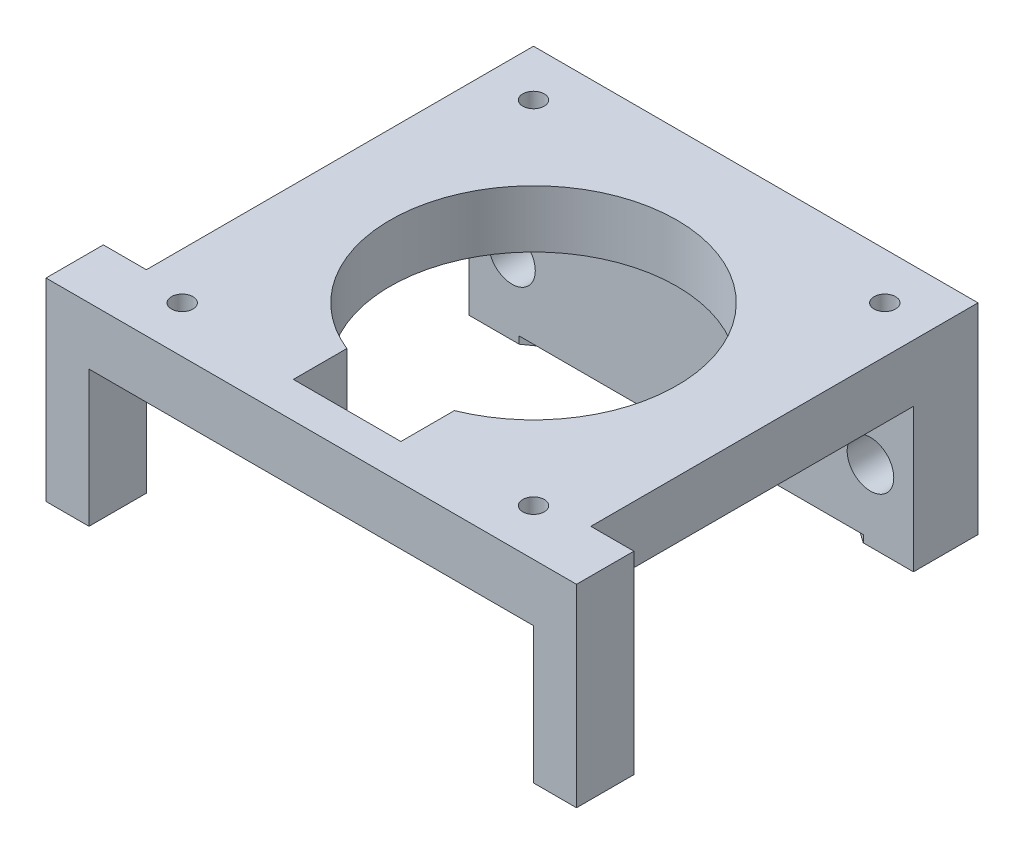
from build123d import *

# Parameters (mm, degrees)
SKETCH1_W           = 31
SKETCH1_H           = 31
SKETCH1_R           = 0.75
SKETCH1_R_2         = 10
BOSS_EXTRUDE1_DEPTH = 4
SKETCH2_W           = 31
SKETCH2_H           = 4.5
BOSS_EXTRUDE2_DEPTH = 10
SKETCH3_R           = 1.625
CUT_EXTRUDE1_DEPTH  = 5.5
SKETCH4_W           = 7.5
SKETCH4_H           = 8
CUT_EXTRUDE2_DEPTH  = 15
SKETCH5_R           = 20
CUT_EXTRUDE3_DEPTH  = 0.5
SKETCH6_W           = 3
SKETCH6_H           = 4
BOSS_EXTRUDE3_DEPTH = 13.5


with BuildPart() as part:
    # Sketch1 → Boss-Extrude1 (new body)
    with BuildSketch(Plane(origin=(0, 0, 0), x_dir=(1, 0, 0), z_dir=(0, 1, 0))):
        Rectangle(SKETCH1_W, SKETCH1_H)
        with Locations((-12.25, 12.25)):
            Circle(SKETCH1_R, mode=Mode.SUBTRACT)
        with Locations((12.25, 12.25)):
            Circle(SKETCH1_R, mode=Mode.SUBTRACT)
        with Locations((12.25, -12.25)):
            Circle(SKETCH1_R, mode=Mode.SUBTRACT)
        with Locations((-12.25, -12.25)):
            Circle(SKETCH1_R, mode=Mode.SUBTRACT)
        Circle(SKETCH1_R_2, mode=Mode.SUBTRACT)
    extrude(amount=BOSS_EXTRUDE1_DEPTH)

    # Sketch2 → Boss-Extrude2 (add)
    with BuildSketch(Plane.XZ):
        with Locations((0, -13.25)):
            Rectangle(SKETCH2_W, SKETCH2_H)
    extrude(amount=BOSS_EXTRUDE2_DEPTH)

    # Sketch3 → Cut-Extrude1 (cut, through all)
    with BuildSketch(Plane.XY.offset(-11)):
        with Locations((-12.5, -5)):
            Circle(SKETCH3_R)
        with Locations((12.5, -5)):
            Circle(SKETCH3_R)
    extrude(amount=-CUT_EXTRUDE1_DEPTH, mode=Mode.SUBTRACT)

    # Sketch4 → Cut-Extrude2 (cut, through all)
    with BuildSketch(Plane(origin=(0, 4, 0), x_dir=(1, 0, 0), z_dir=(0, 1, 0))):
        with Locations((0, -9)):
            Rectangle(SKETCH4_W, SKETCH4_H)
    extrude(amount=-CUT_EXTRUDE2_DEPTH, mode=Mode.SUBTRACT)

    # Sketch5 → Cut-Extrude3 (cut)
    with BuildSketch(Plane.XZ.offset(10)):
        with Locations((0, 5)):
            Circle(SKETCH5_R)
    extrude(amount=-CUT_EXTRUDE3_DEPTH, mode=Mode.SUBTRACT)

    # Sketch6 → Boss-Extrude3 (add)
    with BuildSketch(Plane(origin=(0, 4, 0), x_dir=(1, 0, 0), z_dir=(0, 1, 0))):
        with Locations((-17, -13.5)):
            Rectangle(SKETCH6_W, SKETCH6_H)
        with Locations((17, -13.5)):
            Rectangle(SKETCH6_W, SKETCH6_H)
    extrude(amount=-BOSS_EXTRUDE3_DEPTH)


solid = part.part
